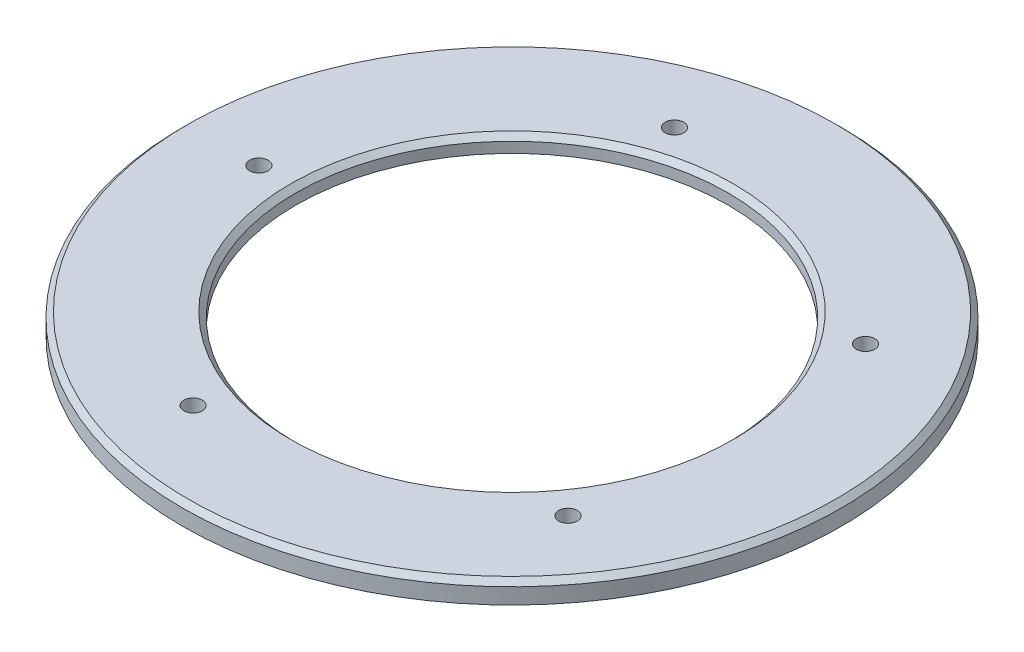
from build123d import *

# Parameters (mm, degrees)
SKETCH2_R          = 1.752085735
CUT_EXTRUDE2_DEPTH = 4
CHAMFER1_SIZE      = 1


with BuildPart() as part:
    # Sketch1 → Revolve1 (revolve)
    with BuildSketch(Plane.XY):
        Polygon((-55, 1), (-55, 0), (-62.5, 0), (-62.5, 4), (-41, 4), (-41, 1), align=None)
    revolve(axis=Axis((0, 0, 0), (0, 1, 0)))

    # Sketch2 → Cut-Extrude2 (cut, through all)
    with BuildSketch(Plane.XZ.offset(-1)):
        with Locations((-48, 0)):
            Circle(SKETCH2_R)
        with Locations((-14.83281573, 45.650712782)):
            Circle(SKETCH2_R)
        with Locations((38.83281573, 28.21369211)):
            Circle(SKETCH2_R)
        with Locations((38.83281573, -28.21369211)):
            Circle(SKETCH2_R)
        with Locations((-14.83281573, -45.650712782)):
            Circle(SKETCH2_R)
    extrude(amount=-CUT_EXTRUDE2_DEPTH, mode=Mode.SUBTRACT)

    # Chamfer1
    chamfer1_edges = [part.edges().sort_by_distance(p)[0] for p in [
        (62.5, 4, 0),
        (41, 4, 0),
    ]]
    chamfer(chamfer1_edges, length=CHAMFER1_SIZE)


solid = part.part
